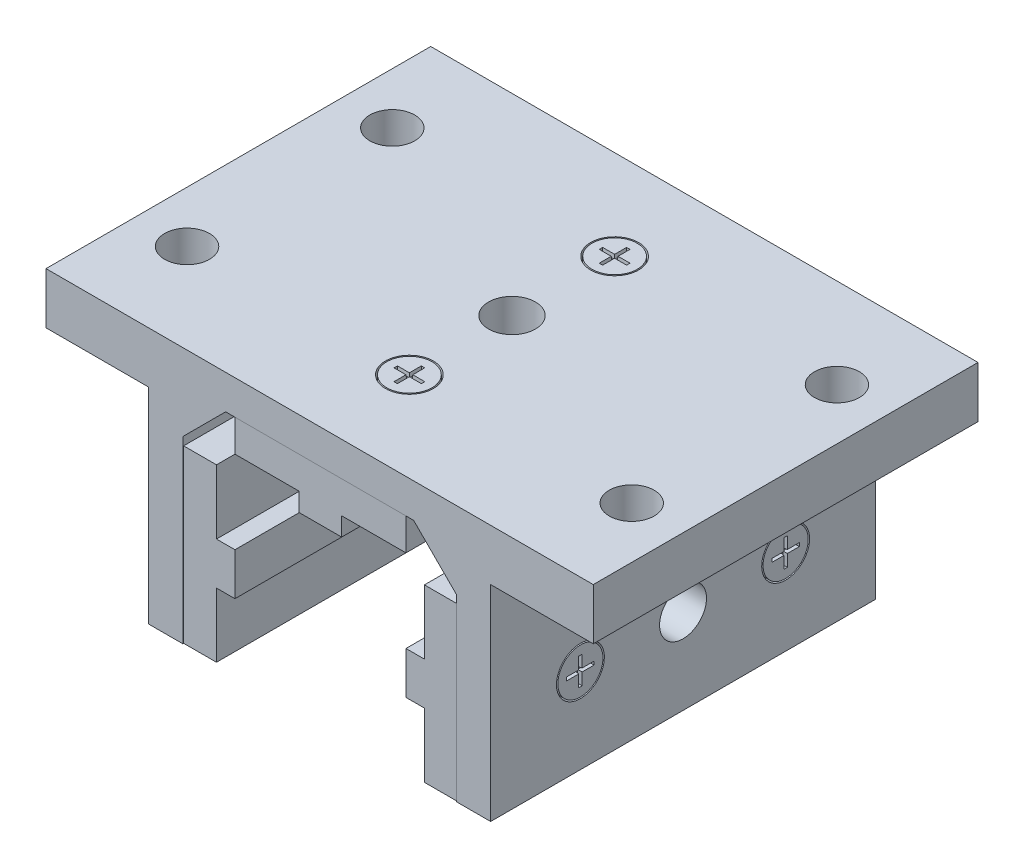
from build123d import *

# Parameters (mm, degrees)
BOSS_EXTRUDE1_DEPTH       = 35.7124
BOSS_EXTRUDE2_DEPTH       = 35.56
BOSS_EXTRUDE2_2_DEPTH     = 35.56
SKETCH11_W                = 7.874
SKETCH11_H                = 7.874
CUT_EXTRUDE5_DEPTH        = 16.875
SKETCH12_W                = 7.874
SKETCH12_H                = 7.874
CUT_EXTRUDE6_DEPTH        = 16.875
SKETCH3_R                 = 4.445
SKETCH3_R_2               = 4.191
CUT_EXTRUDE1_DEPTH        = 3.175
CUT_EXTRUDE2_DEPTH        = 0.762
CUT_EXTRUDE2_TAPER        = 5
SKETCH13_R                = 4.445
SKETCH13_R_2              = 4.191
CUT_EXTRUDE_THIN1_DEPTH   = 3.175
CUT_EXTRUDE7_DEPTH        = 0.762
CUT_EXTRUDE7_TAPER        = 5
MIRROR3_COPY_1_SKETCH_R   = 4.445
MIRROR3_COPY_1_SKETCH_R_2 = 4.191
MIRROR3_COPY_1_DEPTH      = 3.175
MIRROR3_COPY_2_DEPTH      = 0.762
MIRROR3_COPY_2_TAPER      = 5
SKETCH9_R                 = 4.3561
CUT_EXTRUDE4_DEPTH        = 48.625
SKETCH15_R                = 4.3561
CUT_EXTRUDE8_DEPTH        = 32.7500001
CUT_EXTRUDE8_DEPTH_BACK   = 32.7500001
TOP_START                 = -35.7124
SKETCH16_W                = 22.225
SKETCH16_H                = 9.525
TOP_FLANGE_DEPTH          = 71.4248
SKETCH17_R                = 4.1656
TOP_FLANGE_HOLE_DEPTH     = 48.625


with BuildPart() as part:
    # Sketch1 → Boss-Extrude1 (new body, symmetric)
    with BuildSketch(Plane.XY):
        Polygon((-25.4, 0), (-25.4, 33.3248), (-17.4498, 41.275), (17.4498, 41.275), (25.4, 33.3248), (25.4, 0), (31.75, 0), (31.75, 47.625), (-31.75, 47.625), (-31.75, 0), align=None)
    extrude(amount=BOSS_EXTRUDE1_DEPTH, both=True)

    # Sketch3 → Cut-Extrude1 (cut)
    with BuildSketch(Plane(origin=(0, 47.625, 0), x_dir=(1, 0, 0), z_dir=(0, 1, 0))):
        with Locations((0, -19.05)):
            Circle(SKETCH3_R)
        with Locations((0, -19.05)):
            Circle(SKETCH3_R_2, mode=Mode.SUBTRACT)
    cut_extrude1 = extrude(amount=-CUT_EXTRUDE1_DEPTH, mode=Mode.SUBTRACT)

    # Sketch5 → Cut-Extrude2 (cut)
    with BuildSketch(Plane(origin=(0, 47.625, 0), x_dir=(1, 0, 0), z_dir=(0, 1, 0))):
        Polygon((0.3175, -18.7325), (0.3175, -16.51), (-0.3175, -16.51), (-0.3175, -18.7325), (-2.54, -18.7325), (-2.54, -19.3675), (-0.3175, -19.3675), (-0.3175, -21.59), (0.3175, -21.59), (0.3175, -19.3675), (2.54, -19.3675), (2.54, -18.7325), align=None)
    cut_extrude2 = extrude(amount=-CUT_EXTRUDE2_DEPTH, taper=CUT_EXTRUDE2_TAPER, mode=Mode.SUBTRACT)

    # Sketch13 → Cut-Extrude-Thin1 (cut)
    with BuildSketch(Plane(origin=(31.75, 0, 0), x_dir=(0, 0, -1), z_dir=(1, 0, 0))):
        with Locations((-19.05, 15.875)):
            Circle(SKETCH13_R)
        with Locations((-19.05, 15.875)):
            Circle(SKETCH13_R_2, mode=Mode.SUBTRACT)
    cut_extrude_thin1 = extrude(amount=-CUT_EXTRUDE_THIN1_DEPTH, mode=Mode.SUBTRACT)

    # Sketch14 → Cut-Extrude7 (cut)
    with BuildSketch(Plane(origin=(31.75, 0, 0), x_dir=(0, 0, -1), z_dir=(1, 0, 0))):
        Polygon((-19.3675, 15.5575), (-19.3675, 13.335), (-18.7325, 13.335), (-18.7325, 15.5575), (-16.51, 15.5575), (-16.51, 16.1925), (-18.7325, 16.1925), (-18.7325, 18.415), (-19.3675, 18.415), (-19.3675, 16.1925), (-21.59, 16.1925), (-21.59, 15.5575), align=None)
    cut_extrude7 = extrude(amount=-CUT_EXTRUDE7_DEPTH, taper=CUT_EXTRUDE7_TAPER, mode=Mode.SUBTRACT)

    # Mirror4: Cut-Extrude-Thin1, Cut-Extrude7 across plane
    add(cut_extrude_thin1.mirror(Plane(origin=(0, 0, 0), x_dir=(0, 0, 1), z_dir=(1, 0, 0))), mode=Mode.SUBTRACT)
    add(cut_extrude7.mirror(Plane(origin=(0, 0, 0), x_dir=(0, 0, 1), z_dir=(1, 0, 0))), mode=Mode.SUBTRACT)

    # Mirror3: Cut-Extrude-Thin1, Cut-Extrude7, Cut-Extrude1, Cut-Extrude2 across plane
    add(cut_extrude_thin1.mirror(Plane.XY), mode=Mode.SUBTRACT)
    add(cut_extrude7.mirror(Plane.XY), mode=Mode.SUBTRACT)
    add(cut_extrude1.mirror(Plane.XY), mode=Mode.SUBTRACT)
    add(cut_extrude2.mirror(Plane.XY), mode=Mode.SUBTRACT)

    # Mirror3 copy 1 sketch → Mirror3 copy 1 (cut)
    with BuildSketch(Plane.ZY.offset(31.75)):
        with Locations((-19.05, 15.875)):
            Circle(MIRROR3_COPY_1_SKETCH_R)
        with Locations((-19.05, 15.875)):
            Circle(MIRROR3_COPY_1_SKETCH_R_2, mode=Mode.SUBTRACT)
    extrude(amount=-MIRROR3_COPY_1_DEPTH, mode=Mode.SUBTRACT)

    # Mirror3 copy 2 sketch → Mirror3 copy 2 (cut)
    with BuildSketch(Plane.ZY.offset(31.75)):
        Polygon((-19.3675, 15.5575), (-19.3675, 13.335), (-18.7325, 13.335), (-18.7325, 15.5575), (-16.51, 15.5575), (-16.51, 16.1925), (-18.7325, 16.1925), (-18.7325, 18.415), (-19.3675, 18.415), (-19.3675, 16.1925), (-21.59, 16.1925), (-21.59, 15.5575), align=None)
    extrude(amount=-MIRROR3_COPY_2_DEPTH, taper=MIRROR3_COPY_2_TAPER, mode=Mode.SUBTRACT)

    # Sketch9 → Cut-Extrude4 (cut, through all)
    with BuildSketch(Plane(origin=(0, 47.625, 0), x_dir=(1, 0, 0), z_dir=(0, 1, 0))):
        Circle(SKETCH9_R)
    extrude(amount=-CUT_EXTRUDE4_DEPTH, mode=Mode.SUBTRACT)

    # Sketch15 → Cut-Extrude8 (cut, two sides)
    with BuildSketch(Plane(origin=(0, 0, 0), x_dir=(0, 0, -1), z_dir=(1, 0, 0))) as cut_extrude8_sk:
        with Locations((0, 15.875)):
            Circle(SKETCH15_R)
    extrude(amount=CUT_EXTRUDE8_DEPTH, mode=Mode.SUBTRACT)
    extrude(cut_extrude8_sk.sketch, amount=-CUT_EXTRUDE8_DEPTH_BACK, mode=Mode.SUBTRACT)

    # Sketch16 → Top Flange (add)
    with BuildSketch(Plane.XY.offset(TOP_START)):
        with Locations((-39.6875, 42.8625)):
            Rectangle(SKETCH16_W, SKETCH16_H)
        with Locations((39.6875, 42.8625)):
            Rectangle(SKETCH16_W, SKETCH16_H)
    extrude(amount=TOP_FLANGE_DEPTH)

    # Sketch17 → Top Flange Hole (cut, through all)
    with BuildSketch(Plane(origin=(0, 47.625, 0), x_dir=(1, 0, 0), z_dir=(0, 1, 0))):
        with Locations((41.275, 19.05)):
            Circle(SKETCH17_R)
        with Locations((41.275, -19.05)):
            Circle(SKETCH17_R)
        with Locations((-41.275, 19.05)):
            Circle(SKETCH17_R)
        with Locations((-41.275, -19.05)):
            Circle(SKETCH17_R)
    extrude(amount=-TOP_FLANGE_HOLE_DEPTH, mode=Mode.SUBTRACT)


with BuildPart() as body_2:
    # Sketch2 → Boss-Extrude2 (new body, symmetric)
    with BuildSketch(Plane.XY):
        Polygon((-19.304, 19.812), (-19.304, 31.75), (-25.4, 31.75), (-25.4, 0), (-19.304, 0), (-19.304, 11.938), (-15.875, 11.938), (-15.875, 19.812), align=None)
    extrude(amount=BOSS_EXTRUDE2_DEPTH, both=True)

    # Sketch11 → Cut-Extrude5 (cut, through all)
    with BuildSketch(Plane(origin=(-15.875, 0, 0), x_dir=(0, 0, -1), z_dir=(1, 0, 0))):
        with Locations((0, 15.875)):
            Rectangle(SKETCH11_W, SKETCH11_H)
    extrude(amount=-CUT_EXTRUDE5_DEPTH, mode=Mode.SUBTRACT)


with BuildPart() as body_3:
    # Sketch2 → Boss-Extrude2 2 (new body, symmetric)
    with BuildSketch(Plane.XY):
        Polygon((-15.875, 41.275), (15.875, 41.275), (15.875, 35.179), (3.937, 35.179), (3.937, 31.75), (-3.937, 31.75), (-3.937, 35.179), (-15.875, 35.179), align=None)
    extrude(amount=BOSS_EXTRUDE2_2_DEPTH, both=True)

    # Sketch12 → Cut-Extrude6 (cut, through all)
    with BuildSketch(Plane.XZ.offset(-31.75)):
        Rectangle(SKETCH12_W, SKETCH12_H)
    extrude(amount=-CUT_EXTRUDE6_DEPTH, mode=Mode.SUBTRACT)


with BuildPart() as body_4:
    # Mirror1: mirrored copy
    add(body_2.part.mirror(Plane(origin=(0, 0, 0), x_dir=(0, 0, 1), z_dir=(1, 0, 0))))


solid = Compound([part.part, body_2.part, body_3.part, body_4.part])
